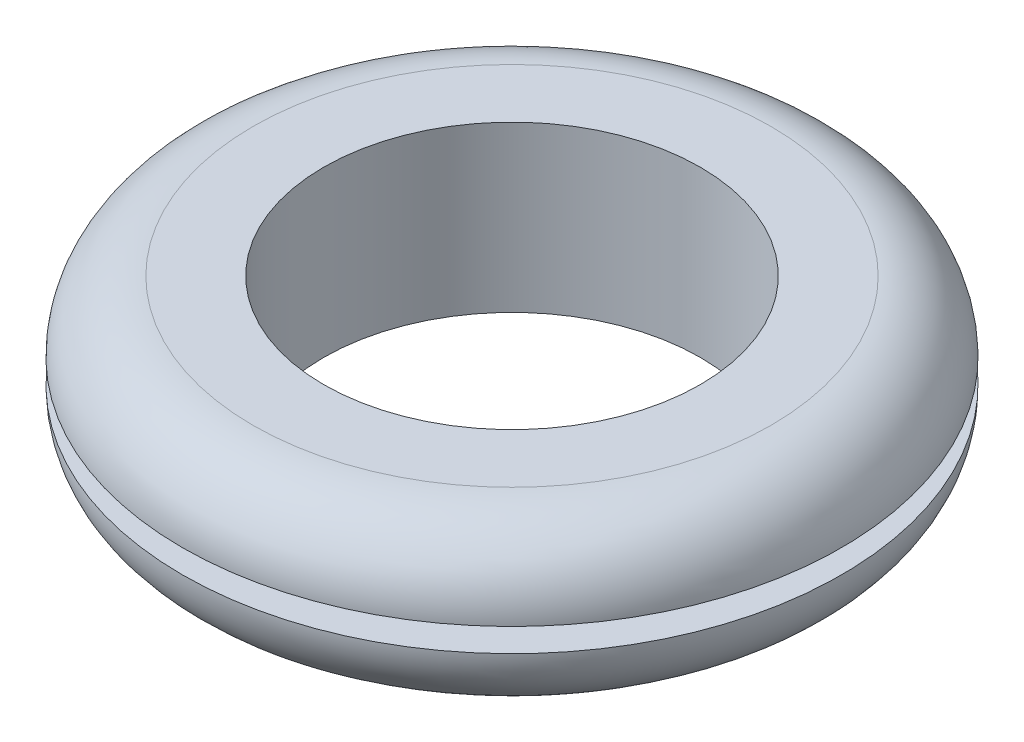
from build123d import *


with BuildPart() as part:
    # Sketch2 → Revolve1 (revolve)
    with BuildSketch(Plane(origin=(0, 0, 0), x_dir=(0, 0, -1), z_dir=(1, 0, 0))):
        with BuildLine():
            Line((-12.7, -5.55625), (-12.7, 5.55625))
            Line((-12.7, 5.55625), (-17.4625, 5.55625))
            ThreePointArc((-17.4625, 5.55625), (-20.830096045, 4.161346045), (-22.225, 0.79375))
            Line((-22.225, 0.79375), (-17.4625, 0.79375))
            Line((-17.4625, 0.79375), (-17.4625, -0.79375))
            Line((-17.4625, -0.79375), (-22.225, -0.79375))
            ThreePointArc((-22.225, -0.79375), (-20.830096045, -4.161346045), (-17.4625, -5.55625))
            Line((-17.4625, -5.55625), (-12.7, -5.55625))
        make_face()
    revolve(axis=Axis((0, -5.55625, 0), (0, 1, 0)))


solid = part.part
